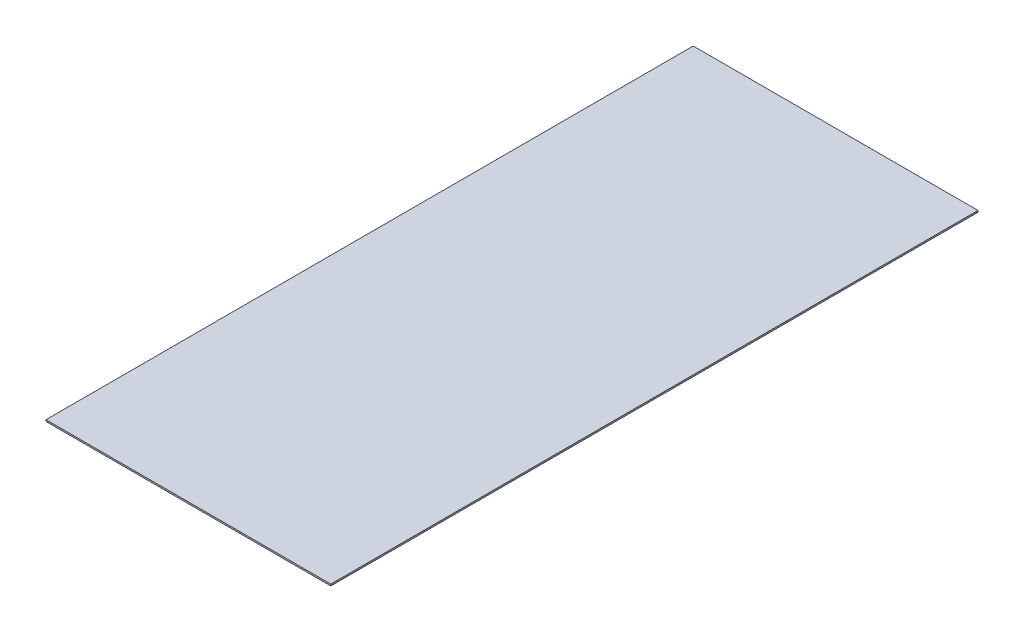
from build123d import *

# Parameters (mm, degrees)
SKETCH1_W           = 279.4
SKETCH1_H           = 1.5875
BOSS_EXTRUDE1_DEPTH = 635


with BuildPart() as part:
    # Sketch1 → Boss-Extrude1 (new body)
    with BuildSketch(Plane.XY):
        Rectangle(SKETCH1_W, SKETCH1_H)
    extrude(amount=BOSS_EXTRUDE1_DEPTH)


solid = part.part
